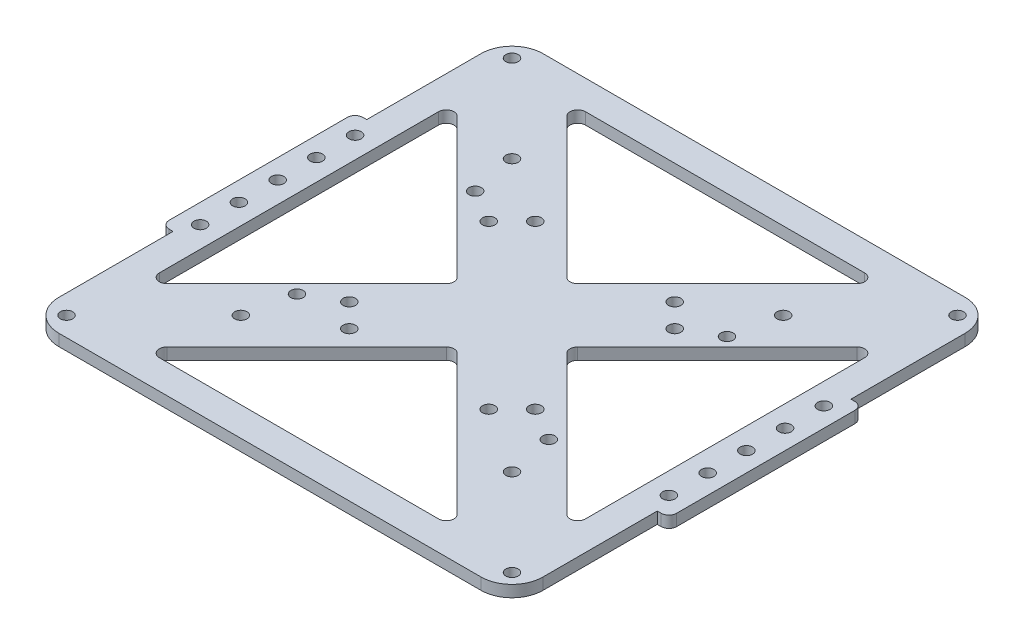
from build123d import *

# Parameters (mm, degrees)
SKETCH_1_R          = 1.6
SKETCH_1_W          = 7
SKETCH_1_H          = 50
EXTRUDE_2_DEPTH     = 3
CUT_EXTRUDE_2_DEPTH = 4


with BuildPart() as part:
    # 草图1 → 凸台-拉伸2 (new body)
    with BuildSketch(Plane(origin=(0, 0, 0), x_dir=(1, 0, 0), z_dir=(0, 1, 0))):
        with BuildLine():
            ThreePointArc((-62.5, -54.5), (-60.156854249, -60.156854249), (-54.5, -62.5))
            Line((-54.5, -62.5), (54.5, -62.5))
            ThreePointArc((54.5, -62.5), (60.156854249, -60.156854249), (62.5, -54.5))
            Line((62.5, -54.5), (62.5, -25))
            Line((62.5, -25), (55.5, -25))
            Line((55.5, -25), (55.5, 25))
            Line((55.5, 25), (62.5, 25))
            Line((62.5, 25), (62.5, 54.5))
            ThreePointArc((62.5, 54.5), (60.156854249, 60.156854249), (54.5, 62.5))
            Line((54.5, 62.5), (-54.5, 62.5))
            ThreePointArc((-54.5, 62.5), (-60.156854249, 60.156854249), (-62.5, 54.5))
            Line((-62.5, 54.5), (-62.5, 25))
            Line((-62.5, 25), (-55.5, 25))
            Line((-55.5, 25), (-55.5, -25))
            Line((-55.5, -25), (-62.5, -25))
            Line((-62.5, -25), (-62.5, -54.5))
        make_face()
        with Locations((-57.5, -57.5)):
            Circle(SKETCH_1_R, mode=Mode.SUBTRACT)
        with Locations((-35, -35)):
            Circle(SKETCH_1_R, mode=Mode.SUBTRACT)
        with Locations((-18, -24)):
            Circle(SKETCH_1_R, mode=Mode.SUBTRACT)
        with Locations((-32.5, -23)):
            Circle(SKETCH_1_R, mode=Mode.SUBTRACT)
        with Locations((-24, -18)):
            Circle(SKETCH_1_R, mode=Mode.SUBTRACT)
        with Locations((57.5, -57.5)):
            Circle(SKETCH_1_R, mode=Mode.SUBTRACT)
        with Locations((35, -35)):
            Circle(SKETCH_1_R, mode=Mode.SUBTRACT)
        with Locations((18, -24)):
            Circle(SKETCH_1_R, mode=Mode.SUBTRACT)
        with Locations((24, -18)):
            Circle(SKETCH_1_R, mode=Mode.SUBTRACT)
        with Locations((32.5, -23)):
            Circle(SKETCH_1_R, mode=Mode.SUBTRACT)
        with Locations((-32.5, 23)):
            Circle(SKETCH_1_R, mode=Mode.SUBTRACT)
        with Locations((-24, 18)):
            Circle(SKETCH_1_R, mode=Mode.SUBTRACT)
        with Locations((-18, 24)):
            Circle(SKETCH_1_R, mode=Mode.SUBTRACT)
        with Locations((-35, 35)):
            Circle(SKETCH_1_R, mode=Mode.SUBTRACT)
        with Locations((-57.5, 57.5)):
            Circle(SKETCH_1_R, mode=Mode.SUBTRACT)
        with Locations((24, 18)):
            Circle(SKETCH_1_R, mode=Mode.SUBTRACT)
        with Locations((32.5, 23)):
            Circle(SKETCH_1_R, mode=Mode.SUBTRACT)
        with Locations((18, 24)):
            Circle(SKETCH_1_R, mode=Mode.SUBTRACT)
        with Locations((35, 35)):
            Circle(SKETCH_1_R, mode=Mode.SUBTRACT)
        with Locations((57.5, 57.5)):
            Circle(SKETCH_1_R, mode=Mode.SUBTRACT)
        with BuildLine():
            ThreePointArc((-62.5, -54.5), (-60.156854249, -60.156854249), (-54.5, -62.5))
            Line((-54.5, -62.5), (54.5, -62.5))
            ThreePointArc((54.5, -62.5), (60.156854249, -60.156854249), (62.5, -54.5))
            Line((62.5, -54.5), (62.5, -25))
            Line((62.5, -25), (55.5, -25))
            Line((55.5, -25), (55.5, 25))
            Line((55.5, 25), (62.5, 25))
            Line((62.5, 25), (62.5, 54.5))
            ThreePointArc((62.5, 54.5), (60.156854249, 60.156854249), (54.5, 62.5))
            Line((54.5, 62.5), (-54.5, 62.5))
            ThreePointArc((-54.5, 62.5), (-60.156854249, 60.156854249), (-62.5, 54.5))
            Line((-62.5, 54.5), (-62.5, 25))
            Line((-62.5, 25), (-55.5, 25))
            Line((-55.5, 25), (-55.5, -25))
            Line((-55.5, -25), (-62.5, -25))
            Line((-62.5, -25), (-62.5, -54.5))
        make_face()
        with Locations((-57.5, -57.5)):
            Circle(SKETCH_1_R, mode=Mode.SUBTRACT)
        with Locations((-35, -35)):
            Circle(SKETCH_1_R, mode=Mode.SUBTRACT)
        with Locations((-18, -24)):
            Circle(SKETCH_1_R, mode=Mode.SUBTRACT)
        with Locations((-32.5, -23)):
            Circle(SKETCH_1_R, mode=Mode.SUBTRACT)
        with Locations((-24, -18)):
            Circle(SKETCH_1_R, mode=Mode.SUBTRACT)
        with Locations((57.5, -57.5)):
            Circle(SKETCH_1_R, mode=Mode.SUBTRACT)
        with Locations((35, -35)):
            Circle(SKETCH_1_R, mode=Mode.SUBTRACT)
        with Locations((18, -24)):
            Circle(SKETCH_1_R, mode=Mode.SUBTRACT)
        with Locations((24, -18)):
            Circle(SKETCH_1_R, mode=Mode.SUBTRACT)
        with Locations((32.5, -23)):
            Circle(SKETCH_1_R, mode=Mode.SUBTRACT)
        with Locations((-32.5, 23)):
            Circle(SKETCH_1_R, mode=Mode.SUBTRACT)
        with Locations((-24, 18)):
            Circle(SKETCH_1_R, mode=Mode.SUBTRACT)
        with Locations((-18, 24)):
            Circle(SKETCH_1_R, mode=Mode.SUBTRACT)
        with Locations((-35, 35)):
            Circle(SKETCH_1_R, mode=Mode.SUBTRACT)
        with Locations((-57.5, 57.5)):
            Circle(SKETCH_1_R, mode=Mode.SUBTRACT)
        with Locations((24, 18)):
            Circle(SKETCH_1_R, mode=Mode.SUBTRACT)
        with Locations((32.5, 23)):
            Circle(SKETCH_1_R, mode=Mode.SUBTRACT)
        with Locations((18, 24)):
            Circle(SKETCH_1_R, mode=Mode.SUBTRACT)
        with Locations((35, 35)):
            Circle(SKETCH_1_R, mode=Mode.SUBTRACT)
        with Locations((57.5, 57.5)):
            Circle(SKETCH_1_R, mode=Mode.SUBTRACT)
        with Locations((-59, 0)):
            Rectangle(SKETCH_1_W, SKETCH_1_H)
        with Locations((-60.5, -20)):
            Circle(SKETCH_1_R, mode=Mode.SUBTRACT)
        with Locations((-60.5, -10)):
            Circle(SKETCH_1_R, mode=Mode.SUBTRACT)
        with Locations((-60.5, 0)):
            Circle(SKETCH_1_R, mode=Mode.SUBTRACT)
        with Locations((-60.5, 10)):
            Circle(SKETCH_1_R, mode=Mode.SUBTRACT)
        with Locations((-60.5, 20)):
            Circle(SKETCH_1_R, mode=Mode.SUBTRACT)
        with BuildLine():
            Line((-63.5, -25), (-62.5, -25))
            Line((-62.5, -25), (-62.5, 25))
            Line((-62.5, 25), (-63.5, 25))
            ThreePointArc((-63.5, 25), (-64.914213562, 24.414213562), (-65.5, 23))
            Line((-65.5, 23), (-65.5, -23))
            ThreePointArc((-65.5, -23), (-64.914213562, -24.414213562), (-63.5, -25))
        make_face()
        with BuildLine():
            Line((62.5, 25), (62.5, -25))
            Line((62.5, -25), (63.5, -25))
            ThreePointArc((63.5, -25), (64.914213562, -24.414213562), (65.5, -23))
            Line((65.5, -23), (65.5, 23))
            ThreePointArc((65.5, 23), (64.914213562, 24.414213562), (63.5, 25))
            Line((63.5, 25), (62.5, 25))
        make_face()
        with Locations((59, 0)):
            Rectangle(SKETCH_1_W, SKETCH_1_H)
        with Locations((60.5, -20)):
            Circle(SKETCH_1_R, mode=Mode.SUBTRACT)
        with Locations((60.5, -10)):
            Circle(SKETCH_1_R, mode=Mode.SUBTRACT)
        with Locations((60.5, 0)):
            Circle(SKETCH_1_R, mode=Mode.SUBTRACT)
        with Locations((60.5, 10)):
            Circle(SKETCH_1_R, mode=Mode.SUBTRACT)
        with Locations((60.5, 20)):
            Circle(SKETCH_1_R, mode=Mode.SUBTRACT)
    extrude(amount=EXTRUDE_2_DEPTH)

    # 草图2 → 切除-拉伸2 (cut, through all)
    with BuildSketch(Plane(origin=(0, 0, 0), x_dir=(1, 0, 0), z_dir=(0, 1, 0))):
        with BuildLine():
            Line((-51.585786438, 37.443650814), (-15.556349186, 1.414213562))
            ThreePointArc((-15.556349186, 1.414213562), (-14.970562748, 0), (-15.556349186, -1.414213562))
            Line((-15.556349186, -1.414213562), (-51.585786438, -37.443650814))
            ThreePointArc((-51.585786438, -37.443650814), (-53.765366865, -37.877196317), (-55, -36.029437252))
            Line((-55, -36.029437252), (-55, 36.029437252))
            ThreePointArc((-55, 36.029437252), (-53.765366865, 37.877196317), (-51.585786438, 37.443650814))
        make_face()
        with BuildLine():
            Line((-36.029437252, 55), (36.029437252, 55))
            ThreePointArc((36.029437252, 55), (37.877196317, 53.765366865), (37.443650814, 51.585786438))
            Line((37.443650814, 51.585786438), (1.414213562, 15.556349186))
            ThreePointArc((1.414213562, 15.556349186), (0, 14.970562748), (-1.414213562, 15.556349186))
            Line((-1.414213562, 15.556349186), (-37.443650814, 51.585786438))
            ThreePointArc((-37.443650814, 51.585786438), (-37.877196317, 53.765366865), (-36.029437252, 55))
        make_face()
        with BuildLine():
            Line((-36.029437252, -55), (36.029437252, -55))
            ThreePointArc((36.029437252, -55), (37.877196317, -53.765366865), (37.443650814, -51.585786438))
            Line((37.443650814, -51.585786438), (1.414213562, -15.556349186))
            ThreePointArc((1.414213562, -15.556349186), (0, -14.970562748), (-1.414213562, -15.556349186))
            Line((-1.414213562, -15.556349186), (-37.443650814, -51.585786438))
            ThreePointArc((-37.443650814, -51.585786438), (-37.877196317, -53.765366865), (-36.029437252, -55))
        make_face()
        with BuildLine():
            Line((55, 36.029437252), (55, -36.029437252))
            ThreePointArc((55, -36.029437252), (53.765366865, -37.877196317), (51.585786438, -37.443650814))
            Line((51.585786438, -37.443650814), (15.556349186, -1.414213562))
            ThreePointArc((15.556349186, -1.414213562), (14.970562748, 0), (15.556349186, 1.414213562))
            Line((15.556349186, 1.414213562), (51.585786438, 37.443650814))
            ThreePointArc((51.585786438, 37.443650814), (53.765366865, 37.877196317), (55, 36.029437252))
        make_face()
    extrude(amount=CUT_EXTRUDE_2_DEPTH, mode=Mode.SUBTRACT)


solid = part.part
